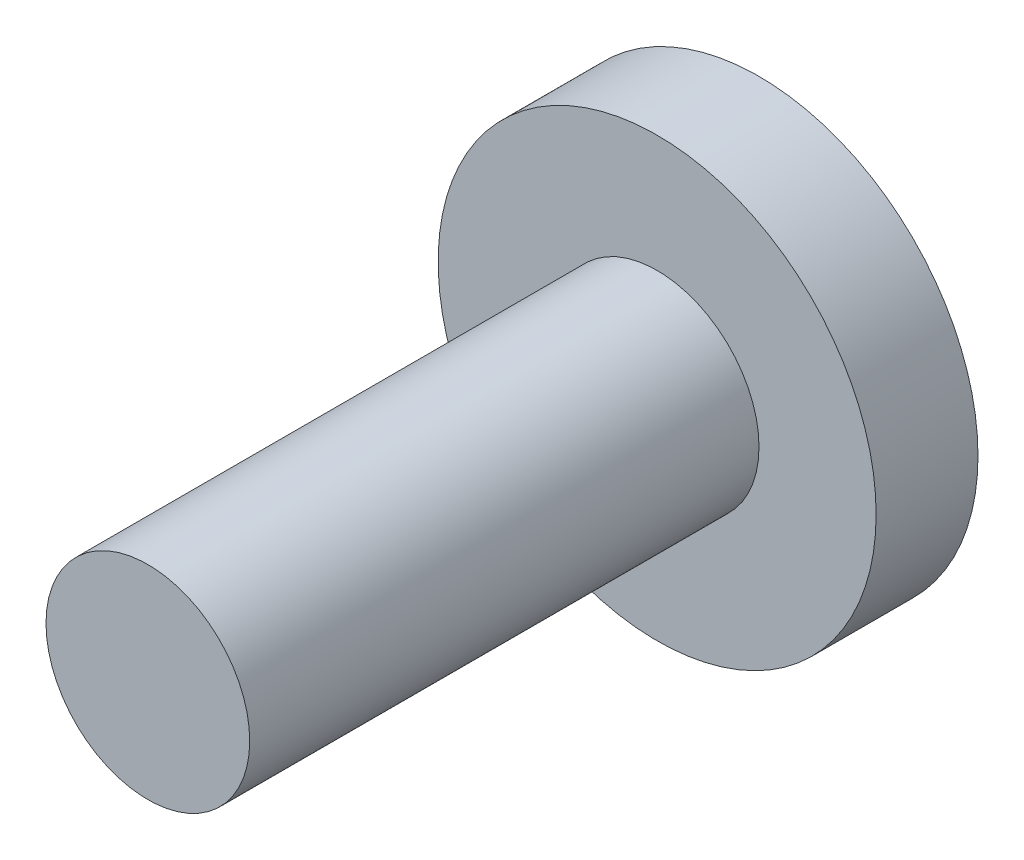
from build123d import *

# Parameters (mm, degrees)
MODEL_R                 = 2.15
SALIENTE_EXTRUIR1_DEPTH = 1
CROQUIS2_R              = 1
SALIENTE_EXTRUIR2_DEPTH = 6


with BuildPart() as part:
    # Model → Saliente-Extruir1 (new body)
    with BuildSketch(Plane.XY):
        with Locations((33.2, 15.9)):
            Circle(MODEL_R)
    extrude(amount=SALIENTE_EXTRUIR1_DEPTH)

    # Croquis2 → Saliente-Extruir2 (add)
    with BuildSketch(Plane.XY):
        with Locations((33.2, 15.9)):
            Circle(CROQUIS2_R)
    extrude(amount=SALIENTE_EXTRUIR2_DEPTH)


solid = part.part
